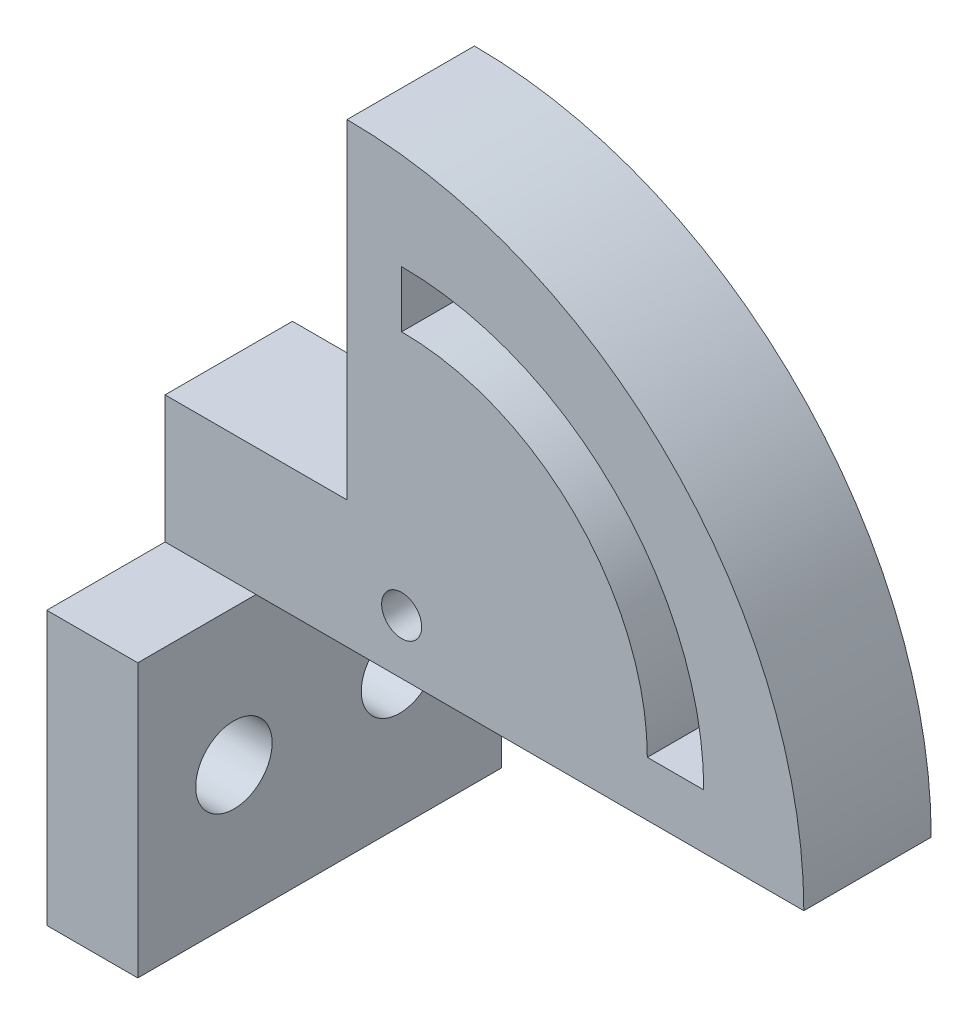
from build123d import *

# Parameters (mm, degrees)
SKETCH1_W           = 25.1
SKETCH1_H           = 7
REVOLVE1_ANGLE      = 90
SKETCH2_W           = 7
SKETCH2_H           = 7
BOSS_EXTRUDE1_DEPTH = 10
SKETCH6_W           = 5
SKETCH6_H           = 7
BOSS_EXTRUDE2_DEPTH = 15
SKETCH7_W           = 5
SKETCH7_H           = 15
BOSS_EXTRUDE3_DEPTH = 6.5
SKETCH8_W           = 5
SKETCH8_H           = 15
BOSS_EXTRUDE4_DEPTH = 6.5
SKETCH10_R          = 2.1
CUT_EXTRUDE8_DEPTH  = 18.5
SKETCH12_R          = 1.1
CUT_EXTRUDE11_DEPTH = 10


with BuildPart() as part:
    # Sketch1 → Revolve1 (revolve)
    with BuildSketch(Plane(origin=(0, 0, 0), x_dir=(1, 0, 0), z_dir=(0, 1, 0))):
        with Locations((12.55, 3.5)):
            Rectangle(SKETCH1_W, SKETCH1_H)
    revolve(axis=Axis((0, 0, 0), (0, 0, 1)), revolution_arc=REVOLVE1_ANGLE)

    # Sketch2 → Boss-Extrude1 (add)
    with BuildSketch(Plane.ZY):
        with Locations((-3.5, 3.5)):
            Rectangle(SKETCH2_W, SKETCH2_H)
    extrude(amount=BOSS_EXTRUDE1_DEPTH)

    # Sketch6 → Boss-Extrude2 (add)
    with BuildSketch(Plane(origin=(0, 0, 0), x_dir=(-1, 0, 0), z_dir=(0, -1, 0))):
        with Locations((7.5, 3.5)):
            Rectangle(SKETCH6_W, SKETCH6_H)
    extrude(amount=BOSS_EXTRUDE2_DEPTH)

    # Sketch7 → Boss-Extrude3 (add)
    with BuildSketch(Plane.XY):
        with Locations((-7.5, -7.5)):
            Rectangle(SKETCH7_W, SKETCH7_H)
    extrude(amount=BOSS_EXTRUDE3_DEPTH)

    # Sketch8 → Boss-Extrude4 (add)
    with BuildSketch(Plane(origin=(0, 0, -7), x_dir=(-1, 0, 0), z_dir=(0, 0, -1))):
        with Locations((7.5, -7.5)):
            Rectangle(SKETCH8_W, SKETCH8_H)
    extrude(amount=BOSS_EXTRUDE4_DEPTH)

    # Sketch10 → Cut-Extrude8 (cut)
    with BuildSketch(Plane(origin=(-5, 0, 0), x_dir=(0, 0, -1), z_dir=(1, 0, 0))):
        with Locations((-1.216, -7.5)):
            Circle(SKETCH10_R)
        with Locations((7.882, -7.5)):
            Circle(SKETCH10_R)
    extrude(amount=-CUT_EXTRUDE8_DEPTH, mode=Mode.SUBTRACT)

    # Sketch12 → Cut-Extrude11 (cut)
    with BuildSketch(Plane.XY):
        with Locations((3, 3)):
            Circle(SKETCH12_R)
        with BuildLine():
            Line((3, 16.5), (3, 19.6))
            ThreePointArc((3, 19.6), (14.737972568, 14.737972568), (19.6, 3))
            Line((19.6, 3), (16.5, 3))
            ThreePointArc((16.5, 3), (12.545941546, 12.545941546), (3, 16.5))
        make_face()
    extrude(amount=-CUT_EXTRUDE11_DEPTH, mode=Mode.SUBTRACT)


solid = part.part
